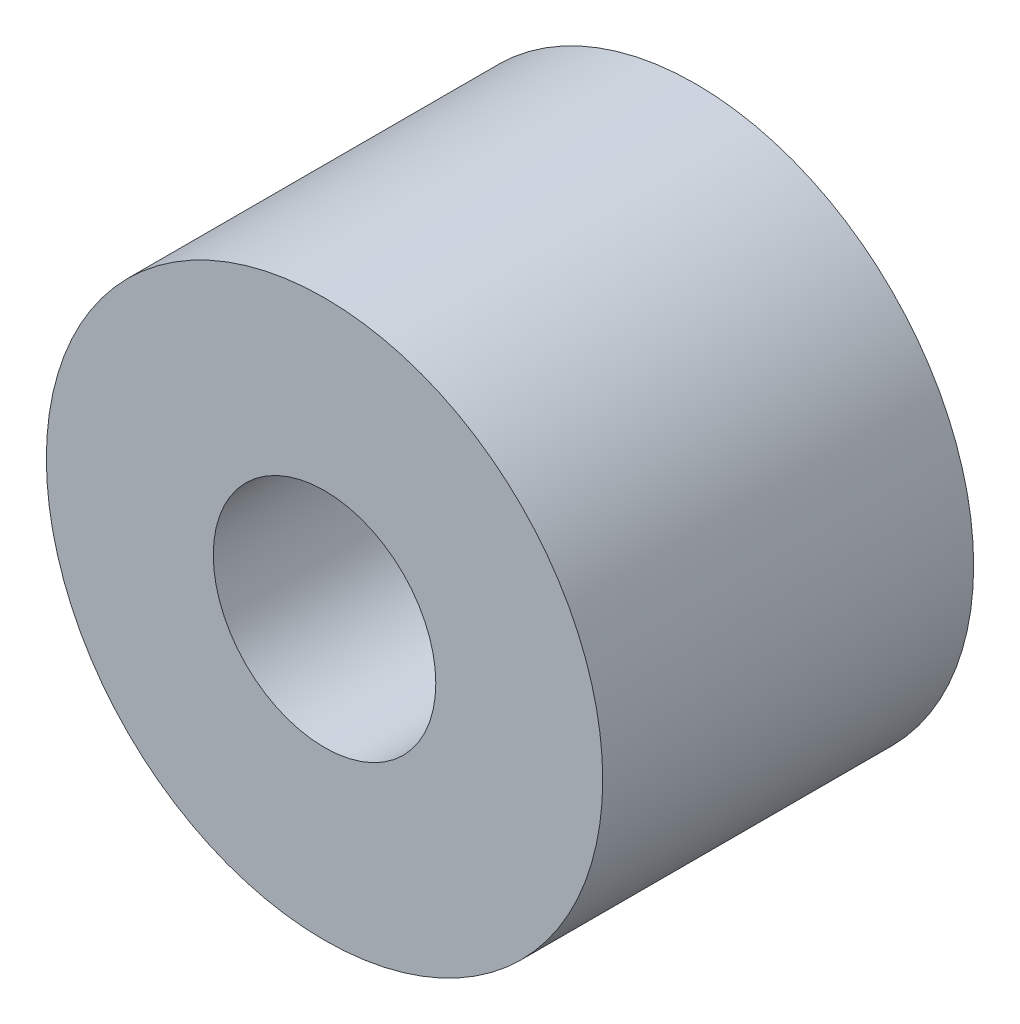
from build123d import *

# Parameters (mm, degrees)
SCHIZZO1_R                   = 22.5
SCHIZZO1_R_2                 = 9
ESTRUSIONE_ESTRUSIONE1_DEPTH = 30
SCHIZZO3_R                   = 3
ESTRUSIONE_ESTRUSIONE2_DEPTH = 25
SCHIZZO4_R                   = 9
TAGLIO_ESTRUSIONE1_DEPTH     = 40


with BuildPart() as part:
    # Schizzo1 → Estrusione-Estrusione1 (new body)
    with BuildSketch(Plane.XY):
        Circle(SCHIZZO1_R)
        Circle(SCHIZZO1_R_2, mode=Mode.SUBTRACT)
    extrude(amount=ESTRUSIONE_ESTRUSIONE1_DEPTH)

    # Schizzo3 → Estrusione-Estrusione2 (add)
    with BuildSketch(Plane(origin=(0, 0, 0), x_dir=(1, 0, 0), z_dir=(0, 1, 0))):
        with Locations((0, -10)):
            Circle(SCHIZZO3_R)
    extrude(amount=-ESTRUSIONE_ESTRUSIONE2_DEPTH)

    # Schizzo4 → Taglio-Estrusione1 (cut)
    with BuildSketch(Plane.XY.offset(30)):
        Circle(SCHIZZO4_R)
    extrude(amount=-TAGLIO_ESTRUSIONE1_DEPTH, mode=Mode.SUBTRACT)


solid = part.part
